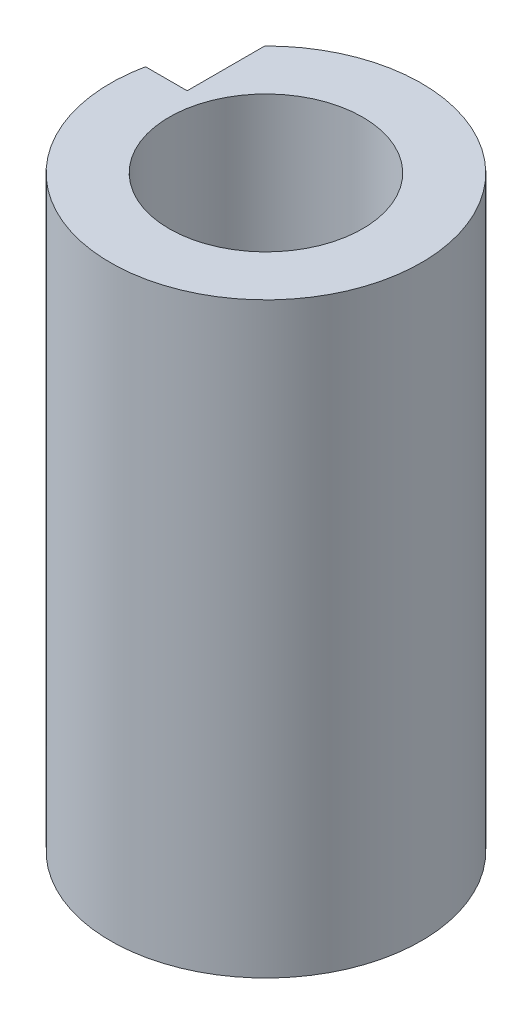
from build123d import *

# Parameters (mm, degrees)
SKETCH1_R           = 1.4
BOSS_EXTRUDE1_DEPTH = 8.5


with BuildPart() as part:
    # Sketch1 → Boss-Extrude1 (new body)
    with BuildSketch(Plane(origin=(0, -3.71400402, 0), x_dir=(1, 0, 0), z_dir=(0, 1, 0))):
        with BuildLine():
            ThreePointArc((-114.649243174, 10.730908874), (-116.044111605, 12.812074413), (-118.499243174, 12.312838076))
            Line((-118.499243174, 12.312838076), (-118.499243174, 11.190908874))
            Line((-118.499243174, 11.190908874), (-119.101719053, 11.190908874))
            ThreePointArc((-119.101719053, 11.190908874), (-117.130467384, 8.49282144), (-114.649243174, 10.730908874))
        make_face()
        with Locations((-116.899243174, 10.730908874)):
            Circle(SKETCH1_R, mode=Mode.SUBTRACT)
    extrude(amount=BOSS_EXTRUDE1_DEPTH)


solid = part.part
